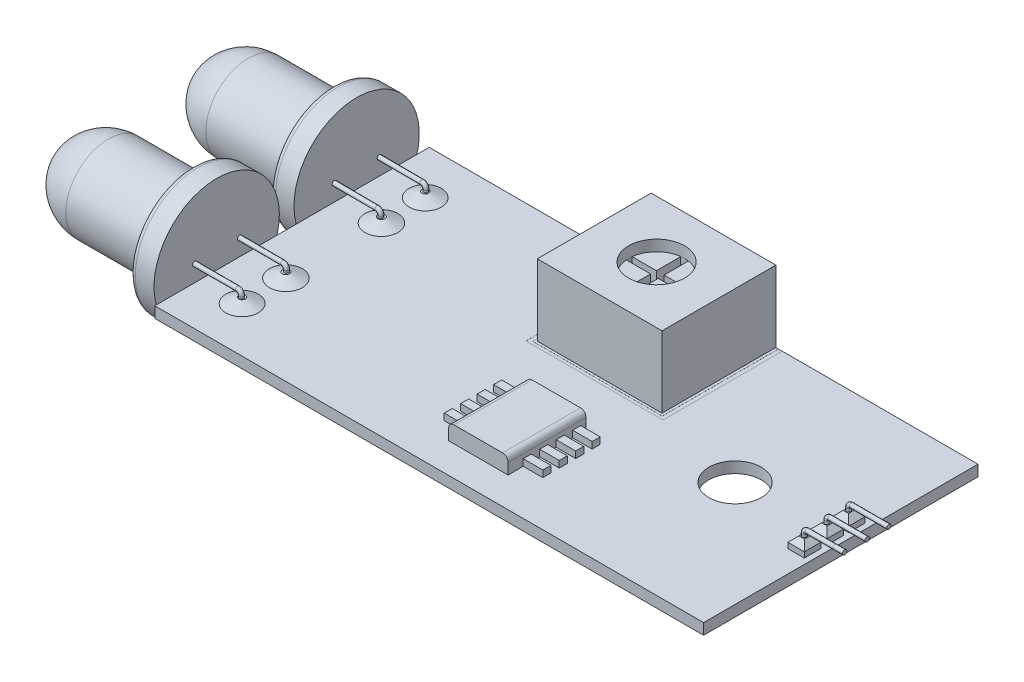
from build123d import *

# Parameters (mm, degrees)
SKETCH2_W                     = 25.4
SKETCH2_H                     = 12.7
BOSS_EXTRUDE1_DEPTH           = 0.508
BOSS_EXTRUDE2_DEPTH           = 0.508
BOSS_EXTRUDE2_DEPTH_BACK      = 0.5334
SKETCH3_W                     = 0.762
SKETCH3_H                     = 0.762
SWEEP1_PROFILE_R              = 0.1016
SWEEP2_PROFILE_R              = 0.1016
SWEEP3_PROFILE_R              = 0.1016
CHAMFER1_SIZE                 = 0.254
SKETCH56_R                    = 0.750565634
BOSS_EXTRUDE4_DEPTH           = 0.254
BOSS_EXTRUDE4_DRAFT           = 67
SKETCH56_R_2                  = 0.762
BOSS_EXTRUDE4_PROFILE_2_DEPTH = 0.254
BOSS_EXTRUDE4_PROFILE_2_DRAFT = 67
BOSS_EXTRUDE4_PROFILE_3_DEPTH = 0.254
BOSS_EXTRUDE4_PROFILE_3_DRAFT = 67
BOSS_EXTRUDE4_PROFILE_4_DEPTH = 0.254
BOSS_EXTRUDE4_PROFILE_4_DRAFT = 67
SKETCH57_W                    = 5.772431141
SKETCH57_H                    = 5.267669161
BOSS_EXTRUDE5_DEPTH           = 3.302
CUT_EXTRUDE1_DEPTH            = 1.27
SKETCH59_R                    = 1.2954
CUT_EXTRUDE2_DEPTH            = 0.508
CUT_EXTRUDE3_DEPTH            = 0.00254
SKETCH61_R                    = 1.215949883
CUT_EXTRUDE4_DEPTH            = 30.686499769
SKETCH62_W                    = 2.750924215
SKETCH62_H                    = 3.607769463
BOSS_EXTRUDE6_DEPTH           = 0.762
SKETCH63_W                    = 0.905284398
SKETCH63_H                    = 0.373042701
SKETCH63_W_2                  = 0.905284397
BOSS_EXTRUDE7_DEPTH           = 0.3048
FILLET1_R                     = 0.254
SWEEP4_PROFILE_R              = 0.1016
SWEEP5_PROFILE_R              = 0.1016
FILLET2_R                     = 0.254
SWEEP6_PROFILE_R              = 0.1016
SWEEP7_PROFILE_R              = 0.1016
FILLET3_R                     = 0.254


with BuildPart() as part:
    # Sketch2 → Boss-Extrude1 (new body)
    with BuildSketch(Plane(origin=(0, 0, 0), x_dir=(1, 0, 0), z_dir=(0, 1, 0))):
        with Locations((12.7, 6.35)):
            Rectangle(SKETCH2_W, SKETCH2_H)
    extrude(amount=BOSS_EXTRUDE1_DEPTH)

    # Sketch3 → Boss-Extrude2 (add, two sides: drawn at the far end of the back side and taken through both)
    with BuildSketch(Plane(origin=(0, 0.508, 0), x_dir=(1, 0, 0), z_dir=(0, 1, 0)).offset(-BOSS_EXTRUDE2_DEPTH_BACK)):
        with Locations((24.765, 7.348034729)):
            Rectangle(SKETCH3_W, SKETCH3_H)
        with Locations((24.765, 6.348327689)):
            Rectangle(SKETCH3_W, SKETCH3_H)
        with Locations((24.765, 5.297788089)):
            Rectangle(SKETCH3_W, SKETCH3_H)
    extrude(amount=BOSS_EXTRUDE2_DEPTH + BOSS_EXTRUDE2_DEPTH_BACK)

    # Boss-Extrude3 cone 1 section (through the dimple's axis) → Boss-Extrude3 (revolve)
    with BuildSketch(Plane(origin=(24.765, -0.0254, -7.348034729), x_dir=(0, 0, 1), z_dir=(1, 0, 0))):
        Polygon((0, 0), (0.322892563, 0), (0, 0.322892563), align=None)
    revolve(axis=Axis((24.765, -0.0254, -7.348034729), (0, -1, 0)))

    # Boss-Extrude3 cone 2 section (through the dimple's axis) → Boss-Extrude3 cone 2 (revolve)
    with BuildSketch(Plane(origin=(24.765, -0.0254, -6.332034729), x_dir=(0, 0, 1), z_dir=(1, 0, 0))):
        Polygon((0, 0), (0.322892563, 0), (0, 0.322892563), align=None)
    revolve(axis=Axis((24.765, -0.0254, -6.332034729), (0, -1, 0)))

    # Boss-Extrude3 cone 3 section (through the dimple's axis) → Boss-Extrude3 cone 3 (revolve)
    with BuildSketch(Plane(origin=(24.765, -0.0254, -5.316034729), x_dir=(0, 0, 1), z_dir=(1, 0, 0))):
        Polygon((0, 0), (0.322892563, 0), (0, 0.322892563), align=None)
    revolve(axis=Axis((24.765, -0.0254, -5.316034729), (0, -1, 0)))

    # Sweep1: sweep along a path in Sketch5
    with BuildLine(Plane.XY.offset(-5.297788089)) as sweep1_path:
        Line((24.765, 0), (24.765, 1.152868242))
        ThreePointArc((24.765, 1.152868242), (24.805117743, 1.249721043), (24.901970544, 1.289838786))
        Line((24.901970544, 1.289838786), (26.180966002, 1.289838786))
        Line((26.180966002, 1.289838786), (26.628838963, 1.289838786))
    # Sweep1 profile (on start of the path) → Sweep1 (sweep)
    with BuildSketch(Plane(origin=(24.765, 0, -5.297788089), x_dir=(0, 0, 1), z_dir=(0, 1, 0))):
        Circle(SWEEP1_PROFILE_R)
    sweep(path=sweep1_path.line)

    # Sweep2: sweep along a path in Sketch26
    with BuildLine(Plane.XY.offset(-6.348327689)) as sweep2_path:
        Line((24.765, 0), (24.765, 1.152868242))
        ThreePointArc((24.765, 1.152868242), (24.805117743, 1.249721043), (24.901970544, 1.289838786))
        Line((24.901970544, 1.289838786), (26.628838963, 1.289838786))
    # Sweep2 profile (on start of the path) → Sweep2 (sweep)
    with BuildSketch(Plane(origin=(24.765, 0, -6.348327689), x_dir=(0, 0, 1), z_dir=(0, 1, 0))):
        Circle(SWEEP2_PROFILE_R)
    sweep(path=sweep2_path.line)

    # Sweep3: sweep along a path in Sketch41
    with BuildLine(Plane.XY.offset(-7.348034729)) as sweep3_path:
        Line((24.765, 0), (24.765, 1.152868242))
        ThreePointArc((24.765, 1.152868242), (24.805117743, 1.249721043), (24.901970544, 1.289838786))
        Line((24.901970544, 1.289838786), (26.628838963, 1.289838786))
    # Sweep3 profile (on start of the path) → Sweep3 (sweep)
    with BuildSketch(Plane(origin=(24.765, 0, -7.348034729), x_dir=(0, 0, 1), z_dir=(0, 1, 0))):
        Circle(SWEEP3_PROFILE_R)
    sweep(path=sweep3_path.line)

    # Chamfer1
    chamfer1_edges = [part.edges().sort_by_distance(p)[0] for p in [
        (25.146, 1.016, -6.348327689),
        (24.765, 1.016, -6.729327689),
        (24.384, 1.016, -6.348327689),
        (24.765, 1.016, -5.967327689),
        (25.146, 1.016, -7.348034729),
        (24.765, 1.016, -7.729034729),
        (24.384, 1.016, -7.348034729),
        (24.765, 1.016, -6.967034729),
        (25.146, 1.016, -5.297788089),
        (24.765, 1.016, -5.678788089),
        (24.384, 1.016, -5.297788089),
        (24.765, 1.016, -4.916788089),
    ]]
    chamfer(chamfer1_edges, length=CHAMFER1_SIZE)


with BuildPart() as boss_extrude4_tool:
    # Sketch56 → Boss-Extrude4 (with draft: the straight prism first)
    with BuildSketch(Plane(origin=(0, 0.508, 0), x_dir=(1, 0, 0), z_dir=(0, 1, 0))):
        with Locations((1.927397114, 10.589129119)):
            Circle(SKETCH56_R)
    extrude(amount=BOSS_EXTRUDE4_DEPTH)
    # Boss-Extrude4: the draft: its side faces are tilted about the plane it starts from
    boss_extrude4_sides = [boss_extrude4_tool.faces().sort_by_distance(p)[0] for p in [
        (1.17683148, 0.635, -10.589129119),
    ]]
    draft(boss_extrude4_sides, Plane(origin=(0, 0.508, 0), x_dir=(1, 0, 0), z_dir=(0, 1, 0)), BOSS_EXTRUDE4_DRAFT)


with BuildPart() as part_1:
    add(part.part)

    # Boss-Extrude4: add boss_extrude4_tool
    add(boss_extrude4_tool.part)


with BuildPart() as boss_extrude4_profile_2_tool:
    # Sketch56 → Boss-Extrude4 profile 2 (with draft: the straight prism first)
    with BuildSketch(Plane(origin=(0, 0.508, 0), x_dir=(1, 0, 0), z_dir=(0, 1, 0))):
        with Locations((1.927397114, 8.559758796)):
            Circle(SKETCH56_R_2)
    extrude(amount=BOSS_EXTRUDE4_PROFILE_2_DEPTH)
    # Boss-Extrude4 profile 2: the draft: its side faces are tilted about the plane it starts from
    boss_extrude4_profile_2_sides = [boss_extrude4_profile_2_tool.faces().sort_by_distance(p)[0] for p in [
        (1.165397114, 0.635, -8.559758796),
    ]]
    draft(boss_extrude4_profile_2_sides, Plane(origin=(0, 0.508, 0), x_dir=(1, 0, 0), z_dir=(0, 1, 0)), BOSS_EXTRUDE4_PROFILE_2_DRAFT)


with BuildPart() as part_2:
    add(part_1.part)

    # Boss-Extrude4 profile 2: add boss_extrude4_profile_2_tool
    add(boss_extrude4_profile_2_tool.part)


with BuildPart() as boss_extrude4_profile_3_tool:
    # Sketch56 → Boss-Extrude4 profile 3 (with draft: the straight prism first)
    with BuildSketch(Plane(origin=(0, 0.508, 0), x_dir=(1, 0, 0), z_dir=(0, 1, 0))):
        with Locations((1.927397114, 2.110870881)):
            Circle(SKETCH56_R)
    extrude(amount=BOSS_EXTRUDE4_PROFILE_3_DEPTH)
    # Boss-Extrude4 profile 3: the draft: its side faces are tilted about the plane it starts from
    boss_extrude4_profile_3_sides = [boss_extrude4_profile_3_tool.faces().sort_by_distance(p)[0] for p in [
        (1.17683148, 0.635, -2.110870881),
    ]]
    draft(boss_extrude4_profile_3_sides, Plane(origin=(0, 0.508, 0), x_dir=(1, 0, 0), z_dir=(0, 1, 0)), BOSS_EXTRUDE4_PROFILE_3_DRAFT)


with BuildPart() as part_3:
    add(part_2.part)

    # Boss-Extrude4 profile 3: add boss_extrude4_profile_3_tool
    add(boss_extrude4_profile_3_tool.part)


with BuildPart() as boss_extrude4_profile_4_tool:
    # Sketch56 → Boss-Extrude4 profile 4 (with draft: the straight prism first)
    with BuildSketch(Plane(origin=(0, 0.508, 0), x_dir=(1, 0, 0), z_dir=(0, 1, 0))):
        with Locations((1.927397114, 4.140241204)):
            Circle(SKETCH56_R_2)
    extrude(amount=BOSS_EXTRUDE4_PROFILE_4_DEPTH)
    # Boss-Extrude4 profile 4: the draft: its side faces are tilted about the plane it starts from
    boss_extrude4_profile_4_sides = [boss_extrude4_profile_4_tool.faces().sort_by_distance(p)[0] for p in [
        (1.165397114, 0.635, -4.140241204),
    ]]
    draft(boss_extrude4_profile_4_sides, Plane(origin=(0, 0.508, 0), x_dir=(1, 0, 0), z_dir=(0, 1, 0)), BOSS_EXTRUDE4_PROFILE_4_DRAFT)


with BuildPart() as part_4:
    add(part_3.part)

    # Boss-Extrude4 profile 4: add boss_extrude4_profile_4_tool
    add(boss_extrude4_profile_4_tool.part)

    # Sketch57 → Boss-Extrude5 (add)
    with BuildSketch(Plane(origin=(0, 0.508, 0), x_dir=(1, 0, 0), z_dir=(0, 1, 0))):
        with Locations((13.156579568, 10.06616542)):
            Rectangle(SKETCH57_W, SKETCH57_H)
    extrude(amount=BOSS_EXTRUDE5_DEPTH)

    # Sketch58 → Cut-Extrude1 (cut)
    with BuildSketch(Plane(origin=(0, 3.81, 0), x_dir=(1, 0, 0), z_dir=(0, 1, 0))):
        with BuildLine():
            Line((12.992586169, 9.953963787), (12.992586169, 8.784949793))
            ThreePointArc((12.992586169, 8.784949793), (13.170356474, 8.77457047), (13.347864933, 8.788739404))
            Line((13.347864933, 8.788739404), (13.347864933, 9.953963787))
            Line((13.347864933, 9.953963787), (14.443365529, 9.953963787))
            ThreePointArc((14.443365529, 9.953963787), (14.448074975, 10.087306112), (14.439003818, 10.22042286))
            Line((14.439003818, 10.22042286), (13.347864933, 10.22042286))
            Line((13.347864933, 10.22042286), (13.347864933, 11.343591435))
            ThreePointArc((13.347864933, 11.343591435), (13.170356474, 11.357760369), (12.992586169, 11.347381046))
            Line((12.992586169, 11.347381046), (12.992586169, 10.22042286))
            Line((12.992586169, 10.22042286), (11.874155317, 10.22042286))
            ThreePointArc((11.874155317, 10.22042286), (11.86508416, 10.087306112), (11.869793606, 9.953963787))
            Line((11.869793606, 9.953963787), (12.992586169, 9.953963787))
        make_face()
    extrude(amount=-CUT_EXTRUDE1_DEPTH, mode=Mode.SUBTRACT)

    # Sketch59 → Cut-Extrude2 (cut)
    with BuildSketch(Plane(origin=(0, 3.81, 0), x_dir=(1, 0, 0), z_dir=(0, 1, 0))):
        with Locations(Location((13.156579568, 10.066165419, 0), (0, 0, 270))):
            Circle(SKETCH59_R)
    extrude(amount=-CUT_EXTRUDE2_DEPTH, mode=Mode.SUBTRACT)

    # Sketch60 → Cut-Extrude3 (cut)
    with BuildSketch(Plane(origin=(0, 0.508, 0), x_dir=(1, 0, 0), z_dir=(0, 1, 0))):
        Polygon((10.159352357, 7.321723919), (10.159352357, 12.7), (9.999476913, 12.7), (9.999476913, 7.179612413), (16.341202844, 7.179612413), (16.341202844, 12.7), (16.163563462, 12.7), (16.163563462, 7.321723919), align=None)
    extrude(amount=-CUT_EXTRUDE3_DEPTH, mode=Mode.SUBTRACT)

    # Sketch61 → Cut-Extrude4 (cut, through all)
    with BuildSketch(Plane(origin=(0, 0.508, 0), x_dir=(1, 0, 0), z_dir=(0, 1, 0))):
        with Locations(Location((20.507409848, 6.348327689, 0), (0, 0, 270))):
            Circle(SKETCH61_R)
    extrude(amount=-CUT_EXTRUDE4_DEPTH, mode=Mode.SUBTRACT)

    # Sketch62 → Boss-Extrude6 (add)
    with BuildSketch(Plane(origin=(0, 0.508, 0), x_dir=(1, 0, 0), z_dir=(0, 1, 0))):
        with Locations((13.585002192, 3.19320172)):
            Rectangle(SKETCH62_W, SKETCH62_H)
    extrude(amount=BOSS_EXTRUDE6_DEPTH)

    # Sketch63 → Boss-Extrude7 (add)
    with BuildSketch(Plane(origin=(0, 0.508, 0), x_dir=(1, 0, 0), z_dir=(0, 1, 0))):
        with Locations((11.756897885, 4.562746132)):
            Rectangle(SKETCH63_W, SKETCH63_H)
        with Locations((11.756897885, 3.800746132)):
            Rectangle(SKETCH63_W, SKETCH63_H)
        with Locations((11.756897885, 3.038746131)):
            Rectangle(SKETCH63_W, SKETCH63_H)
        with Locations((11.756897885, 2.276746132)):
            Rectangle(SKETCH63_W, SKETCH63_H)
        with Locations((15.413106498, 2.276746132)):
            Rectangle(SKETCH63_W_2, SKETCH63_H)
        with Locations((15.413106498, 3.038746131)):
            Rectangle(SKETCH63_W_2, SKETCH63_H)
        with Locations((15.413106498, 3.800746132)):
            Rectangle(SKETCH63_W_2, SKETCH63_H)
        with Locations((15.413106498, 4.562746132)):
            Rectangle(SKETCH63_W_2, SKETCH63_H)
    extrude(amount=BOSS_EXTRUDE7_DEPTH)

    # Fillet1
    fillet1_edges = [part_4.edges().sort_by_distance(p)[0] for p in [
        (12.209540084, 1.27, -3.19320172),
        (14.960464299, 1.27, -3.19320172),
    ]]
    fillet(fillet1_edges, radius=FILLET1_R)

    # Sweep4: sweep along a path in Sketch64
    with BuildLine(Plane.XY.offset(-2.0828)) as sweep4_path:
        Line((1.927397114, 0.206781829), (1.927397114, 0.858271013))
        ThreePointArc((1.927397114, 0.858271013), (1.875894773, 0.982608664), (1.751557121, 1.034111006))
        Line((1.751557121, 1.034111006), (-0.573291951, 1.034111006))
    # Sweep4 profile (on start of the path) → Sweep4 (sweep)
    with BuildSketch(Plane(origin=(1.927397114, 0.206781829, -2.0828), x_dir=(0, 0, 1), z_dir=(0, 1, 0))):
        Circle(SWEEP4_PROFILE_R)
    sweep(path=sweep4_path.line)

    # Sweep5: sweep along a path in Sketch79
    with BuildLine(Plane.XY.offset(-4.1656)) as sweep5_path:
        Line((1.927397114, 0.223613493), (1.927397114, 0.858271013))
        ThreePointArc((1.927397114, 0.858271013), (1.875894773, 0.982608664), (1.751557121, 1.034111006))
        Line((1.751557121, 1.034111006), (-0.573291951, 1.034111006))
    # Sweep5 profile (on start of the path) → Sweep5 (sweep)
    with BuildSketch(Plane(origin=(1.927397114, 0.223613493, -4.1656), x_dir=(0, 0, 1), z_dir=(0, 1, 0))):
        Circle(SWEEP5_PROFILE_R)
    sweep(path=sweep5_path.line)

    # Sketch94 → Revolve1 (revolve)
    with BuildSketch(Plane.XY.offset(-3.0988), mode=Mode.PRIVATE) as revolve1_sk:
        with BuildLine():
            Line((-0.235718486, 1.048024286), (-0.235718486, 3.947467652))
            Line((-0.235718486, 3.947467652), (-1.357300297, 3.947467652))
            Line((-1.357300297, 3.947467652), (-1.357300297, 3.011732114))
            Line((-1.357300297, 3.011732114), (-5.253447551, 3.011732114))
            ThreePointArc((-5.253447551, 3.011732114), (-6.731021216, 2.449800786), (-7.461783421, 1.048024286))
            Line((-7.461783421, 1.048024286), (-0.235718486, 1.048024286))
        make_face()
    revolve(revolve1_sk.sketch.rotate(Axis((-0.235718486, 1.048024286, -3.0988), (-1, 0, 0)), 90), axis=Axis((-0.235718486, 1.048024286, -3.0988), (-1, 0, 0)))

    # Fillet2
    fillet2_edges = [part_4.edges().sort_by_distance(p)[0] for p in [
        (-1.357300297, 1.048024286, -0.199356634),
        (-1.357300297, 1.048024286, -1.135092173),
    ]]
    fillet(fillet2_edges, radius=FILLET2_R)

    # Sweep6: sweep along a path in Sketch95
    with BuildLine(Plane(origin=(0, 0, -8.5344), x_dir=(-1, 0, 0), z_dir=(0, 0, -1))) as sweep6_path:
        Line((-1.927397114, 0.224408237), (-1.927397114, 0.858271013))
        ThreePointArc((-1.927397114, 0.858271013), (-1.875894773, 0.982608664), (-1.751557121, 1.034111006))
        Line((-1.751557121, 1.034111006), (1.103300297, 1.048024286))
    # Sweep6 profile (on start of the path) → Sweep6 (sweep)
    with BuildSketch(Plane(origin=(1.927397114, 0.224408237, -8.5344), x_dir=(0, 0, 1), z_dir=(0, 1, 0))):
        Circle(SWEEP6_PROFILE_R)
    sweep(path=sweep6_path.line, transition=Transition.RIGHT)

    # Sweep7: sweep along a path in Sketch110
    with BuildLine(Plane(origin=(0, 0, -10.6172), x_dir=(-1, 0, 0), z_dir=(0, 0, -1))) as sweep7_path:
        Line((-1.927397114, 0.281415746), (-1.927397114, 0.858271013))
        ThreePointArc((-1.927397114, 0.858271013), (-1.876091608, 0.982133461), (-1.752229159, 1.033438968))
        Line((-1.752229159, 1.033438968), (1.103300297, 1.048024286))
    # Sweep7 profile (on start of the path) → Sweep7 (sweep)
    with BuildSketch(Plane(origin=(1.927397114, 0.281415746, -10.6172), x_dir=(0, 0, 1), z_dir=(0, 1, 0))):
        Circle(SWEEP7_PROFILE_R)
    sweep(path=sweep7_path.line, transition=Transition.RIGHT)

    # Sketch125 → Revolve2 (revolve)
    with BuildSketch(Plane(origin=(0, 0, -9.5758), x_dir=(-1, 0, 0), z_dir=(0, 0, -1)), mode=Mode.PRIVATE) as revolve2_sk:
        with BuildLine():
            ThreePointArc((5.253447551, 3.011732114), (6.731021216, 2.449800786), (7.461783421, 1.048024286))
            Line((7.461783421, 1.048024286), (0.221075853, 1.048024286))
            Line((0.221075853, 1.048024286), (0.235718486, 3.947467652))
            Line((0.235718486, 3.947467652), (1.336079036, 3.947467652))
            Line((1.336079036, 3.947467652), (1.357300297, 3.011732114))
            Line((1.357300297, 3.011732114), (5.253447551, 3.011732114))
        make_face()
    revolve(revolve2_sk.sketch.rotate(Axis((-7.461783421, 1.048024286, -9.5758), (1, 0, 0)), 90), axis=Axis((-7.461783421, 1.048024286, -9.5758), (1, 0, 0)))

    # Fillet3
    fillet3_edges = [part_4.edges().sort_by_distance(p)[0] for p in [
        (-1.357300297, 1.048024286, -11.539507827),
        (-1.336079036, 1.048024286, -12.475243366),
    ]]
    fillet(fillet3_edges, radius=FILLET3_R)


solid = part_4.part
